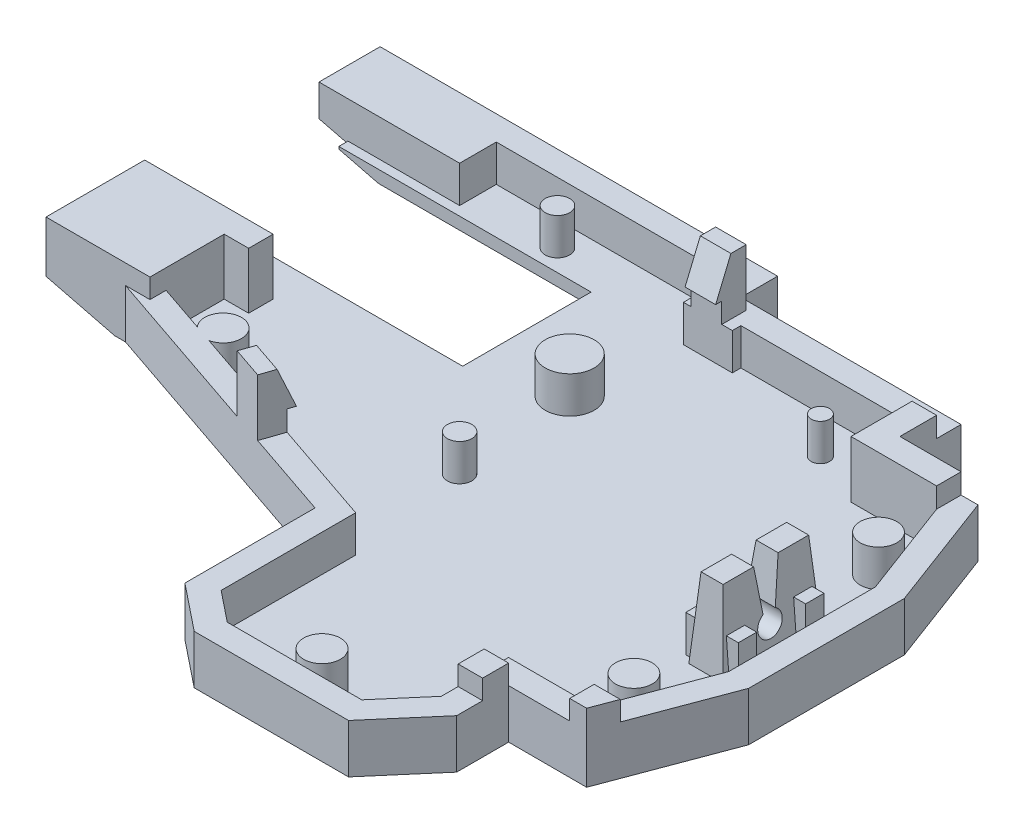
from build123d import *

# Parameters (mm, degrees)
SKETCH13_W           = 50
SKETCH13_H           = 45
BOSS_EXTRUDE4_DEPTH  = 1.6
SKETCH14_W           = 10
SKETCH14_H           = 8
CUT_EXTRUDE6_DEPTH   = 2.6
SKETCH15_W           = 18
SKETCH15_H           = 3
CUT_EXTRUDE7_DEPTH   = 2.6
SKETCH16_W           = 4
SKETCH16_H           = 0.7
CUT_EXTRUDE8_DEPTH   = 2.6
CUT_EXTRUDE9_DEPTH   = 2.6
SKETCH18_W           = 21.109590793
SKETCH18_H           = 22.840524871
CUT_EXTRUDE10_DEPTH  = 2.6
CUT_EXTRUDE11_DEPTH  = 2.6
SKETCH22_W           = 2
SKETCH22_H           = 3
CUT_EXTRUDE12_DEPTH  = 2.6
CUT_EXTRUDE13_DEPTH  = 2.6
CUT_EXTRUDE14_DEPTH  = 2.6
SKETCH25_W           = 2.8
SKETCH25_H           = 8
CUT_EXTRUDE15_DEPTH  = 2.6
BOSS_EXTRUDE6_DEPTH  = 6
SKETCH30_W           = 2.8
SKETCH30_H           = 8
BOSS_EXTRUDE7_DEPTH  = 3.5
CUT_EXTRUDE16_DEPTH  = 4.6
SKETCH32_W           = 2.8
SKETCH32_H           = 8
BOSS_EXTRUDE8_DEPTH  = 4.6
CUT_EXTRUDE18_DEPTH  = 4.6
SKETCH37_R           = 1
CUT_EXTRUDE19_DEPTH  = 4.6
CUT_EXTRUDE20_DEPTH  = 4.6
CUT_EXTRUDE21_START  = 6
CUT_EXTRUDE21_DEPTH  = 20.059798
BOSS_EXTRUDE9_DEPTH  = 4.6
SKETCH44_W           = 4.3
SKETCH44_H           = 1.5
BOSS_EXTRUDE11_DEPTH = 3
SKETCH45_R           = 1.5
SKETCH45_R_2         = 1
SKETCH45_R_3         = 1.999622229
SKETCH45_R_4         = 1.503341979
SKETCH45_R_5         = 0.75
BOSS_EXTRUDE12_DEPTH = 3
SKETCH46_W           = 2.5
SKETCH46_H           = 2
SKETCH46_W_2         = 2
BOSS_EXTRUDE13_DEPTH = 1.65
SKETCH47_W           = 3
SKETCH47_H           = 3
BOSS_EXTRUDE14_DEPTH = 3
SKETCH48_W           = 2
SKETCH48_H           = 16.336241737
CUT_EXTRUDE22_DEPTH  = 3
SKETCH49_W           = 21.336241737
SKETCH49_H           = 3
BOSS_EXTRUDE15_DEPTH = 13
SKETCH50_W           = 67
SKETCH50_H           = 49
BOSS_EXTRUDE16_DEPTH = 3
SKETCH51_W           = 5
SKETCH51_H           = 11
BOSS_EXTRUDE17_DEPTH = 15.6
CUT_EXTRUDE23_DEPTH  = 1.65
SKETCH53_W           = 2
SKETCH53_H           = 2.129349353
BOSS_EXTRUDE18_DEPTH = 1.6
SKETCH55_W           = 2.5
SKETCH55_H           = 2.5
BOSS_EXTRUDE20_DEPTH = 3
CUT_EXTRUDE24_DEPTH  = 3
SKETCH58_W           = 20
SKETCH58_H           = 10.5
SKETCH58_W_2         = 2
SKETCH58_H_2         = 2
CUT_EXTRUDE29_DEPTH  = 1
BOSS_EXTRUDE21_DEPTH = 3
BOSS_EXTRUDE22_REACH = 41.731
SKETCH61_W           = 2.5
SKETCH61_H           = 1.65
CUT_EXTRUDE30_DEPTH  = 3
CUT_EXTRUDE31_REACH  = 43.731
SKETCH64_W           = 2.551500858
SKETCH64_H           = 4.310788114
CUT_EXTRUDE32_DEPTH  = 4.65
SKETCH65_W           = 2
SKETCH65_H           = 2
BOSS_EXTRUDE23_DEPTH = 4
SKETCH66_W           = 2
SKETCH66_H           = 2
BOSS_EXTRUDE24_DEPTH = 1.6
SKETCH67_W           = 2.5
SKETCH67_H           = 2
BOSS_EXTRUDE25_DEPTH = 3
CUT_EXTRUDE33_DEPTH  = 3
BOSS_EXTRUDE26_DEPTH = 1.65
SKETCH70_W           = 5.055009343
SKETCH70_H           = 5.560438358
CUT_EXTRUDE34_DEPTH  = 3
BOSS_EXTRUDE27_DEPTH = 3
CUT_EXTRUDE35_DEPTH  = 3
BOSS_EXTRUDE28_REACH = 39.863
CUT_EXTRUDE36_DEPTH  = 3
FILLET8_R            = 1
SKETCH76_W           = 7
SKETCH76_H           = 14.5
BOSS_EXTRUDE29_DEPTH = 14.5
BOSS_EXTRUDE30_DEPTH = 2
CUT_EXTRUDE37_DEPTH  = 2
BOSS_EXTRUDE31_DEPTH = 2.684479
SKETCH85_W           = 30.566158209
SKETCH85_H           = 1.725230041
BOSS_EXTRUDE33_DEPTH = 3
BOSS_EXTRUDE34_DEPTH = 3
BOSS_EXTRUDE35_DEPTH = 3
SKETCH88_W           = 27.09375
SKETCH88_H           = 14.5
BOSS_EXTRUDE36_DEPTH = 1.6
SKETCH90_W           = 7
SKETCH90_H           = 14.5
BOSS_EXTRUDE37_DEPTH = 1.6
SKETCH93_W           = 5
SKETCH93_H           = 11
BOSS_EXTRUDE38_DEPTH = 0.5
SKETCH94_W           = 8.605758832
SKETCH94_H           = 2
BOSS_EXTRUDE39_DEPTH = 15.6
SKETCH96_W           = 8.605758832
SKETCH96_H           = 2
BOSS_EXTRUDE40_DEPTH = 0.5
SKETCH97_W           = 2
SKETCH97_H           = 49
BOSS_EXTRUDE41_DEPTH = 19.1
SKETCH98_W           = 69
SKETCH98_H           = 2
BOSS_EXTRUDE42_DEPTH = 19.1
SKETCH99_W           = 2
SKETCH99_H           = 3
BOSS_EXTRUDE43_DEPTH = 2.087376
SKETCH100_W          = 2
SKETCH100_H          = 51
BOSS_EXTRUDE45_DEPTH = 19.1
SKETCH101_W          = 71
SKETCH101_H          = 2
BOSS_EXTRUDE46_DEPTH = 19.1
BOSS_EXTRUDE47_DEPTH = 16.1
BOSS_EXTRUDE48_DEPTH = 16.1
FILLET9_R            = 2
SKETCH105_OUTSIDE_W  = 91.128
SKETCH105_OUTSIDE_H  = 73.128
CUT_EXTRUDE38_DEPTH  = 3
SKETCH106_W          = 77.0560479
SKETCH106_H          = 58.523580684
CUT_EXTRUDE39_DEPTH  = 20.1
SKETCH107_W          = 13.37564089
SKETCH107_H          = 6.179627402
CUT_EXTRUDE40_DEPTH  = 11.5
CUT_EXTRUDE41_DEPTH  = 4
SKETCH114_W          = 66.336817547
SKETCH114_H          = 51.668552302
CUT_EXTRUDE42_DEPTH  = 2
BOSS_EXTRUDE49_DEPTH = 6.5
SKETCH116_W          = 0.628599621
SKETCH116_H          = 10.5
CUT_EXTRUDE43_DEPTH  = 6.5
SKETCH117_W          = 8.5
SKETCH117_H          = 8.070282703
BOSS_EXTRUDE50_DEPTH = 1.6
SKETCH122_W          = 25.874774146
SKETCH122_H          = 74.423318024
CUT_EXTRUDE44_DEPTH  = 2.358414017


with BuildPart() as part:
    # Sketch13 → Boss-Extrude4 (new body)
    with BuildSketch(Plane(origin=(0, 0, 0), x_dir=(1, 0, 0), z_dir=(0, 1, 0))):
        with Locations((25, -22.5)):
            Rectangle(SKETCH13_W, SKETCH13_H)
    extrude(amount=BOSS_EXTRUDE4_DEPTH)

    # Sketch14 → Cut-Extrude6 (cut, through all)
    with BuildSketch(Plane(origin=(0, 1.6, 0), x_dir=(1, 0, 0), z_dir=(0, 1, 0))):
        with Locations((45, -4)):
            Rectangle(SKETCH14_W, SKETCH14_H)
    extrude(amount=-CUT_EXTRUDE6_DEPTH, mode=Mode.SUBTRACT)

    # Sketch15 → Cut-Extrude7 (cut, through all)
    with BuildSketch(Plane(origin=(0, 1.6, 0), x_dir=(1, 0, 0), z_dir=(0, 1, 0))):
        with Locations((31, -1.5)):
            Rectangle(SKETCH15_W, SKETCH15_H)
    extrude(amount=-CUT_EXTRUDE7_DEPTH, mode=Mode.SUBTRACT)

    # Sketch16 → Cut-Extrude8 (cut, through all)
    with BuildSketch(Plane(origin=(0, 1.6, 0), x_dir=(1, 0, 0), z_dir=(0, 1, 0))):
        with Locations((24, -3.35)):
            Rectangle(SKETCH16_W, SKETCH16_H)
    extrude(amount=-CUT_EXTRUDE8_DEPTH, mode=Mode.SUBTRACT)

    # Sketch17 → Cut-Extrude9 (cut, through all)
    with BuildSketch(Plane(origin=(0, 1.6, 0), x_dir=(1, 0, 0), z_dir=(0, 1, 0))):
        Polygon((47, -8), (50, -16), (65.881056194, -16), (65.881056194, 17.957346821), (47, 17.957346821), align=None)
    extrude(amount=-CUT_EXTRUDE9_DEPTH, mode=Mode.SUBTRACT)

    # Sketch18 → Cut-Extrude10 (cut, through all)
    with BuildSketch(Plane(origin=(0, 1.6, 0), x_dir=(1, 0, 0), z_dir=(0, 1, 0))):
        with Locations((50.554795396, -47.420262436)):
            Rectangle(SKETCH18_W, SKETCH18_H)
    extrude(amount=-CUT_EXTRUDE10_DEPTH, mode=Mode.SUBTRACT)

    # Sketch21 → Cut-Extrude11 (cut, through all)
    with BuildSketch(Plane(origin=(0, 1.6, 0), x_dir=(1, 0, 0), z_dir=(0, 1, 0))):
        Polygon((50, -28), (47, -36), (47, -49.297594069), (75.196774358, -49.297594069), (75.196774358, -28), align=None)
    extrude(amount=-CUT_EXTRUDE11_DEPTH, mode=Mode.SUBTRACT)

    # Sketch22 → Cut-Extrude12 (cut, through all)
    with BuildSketch(Plane(origin=(0, 1.6, 0), x_dir=(1, 0, 0), z_dir=(0, 1, 0))):
        with Locations((1, -20.836241737)):
            Rectangle(SKETCH22_W, SKETCH22_H)
    extrude(amount=-CUT_EXTRUDE12_DEPTH, mode=Mode.SUBTRACT)

    # Sketch23 → Cut-Extrude13 (cut, through all)
    with BuildSketch(Plane(origin=(0, 1.6, 0), x_dir=(1, 0, 0), z_dir=(0, 1, 0))):
        Polygon((23.5, -45), (23.5, -32), (0, -26.336241737), (-30.2261683, -26.336241737), (-30.2261683, -63.188280898), (23.5, -63.188280898), align=None)
    extrude(amount=-CUT_EXTRUDE13_DEPTH, mode=Mode.SUBTRACT)

    # Sketch24 → Cut-Extrude14 (cut, through all)
    with BuildSketch(Plane(origin=(0, 1.6, 0), x_dir=(1, 0, 0), z_dir=(0, 1, 0))):
        Polygon((23.5, -43), (7.491129632, -43), (7.491129632, -69.550234766), (44.754002286, -69.550234766), (44.754002286, -41.5), (40, -41.5), (37, -45), (26, -45), align=None)
    extrude(amount=-CUT_EXTRUDE14_DEPTH, mode=Mode.SUBTRACT)

    # Sketch25 → Cut-Extrude15 (cut, through all)
    with BuildSketch(Plane(origin=(0, 1.6, 0), x_dir=(1, 0, 0), z_dir=(0, 1, 0))):
        with Locations((46.200745069, -22.059797812)):
            Rectangle(SKETCH25_W, SKETCH25_H)
    extrude(amount=-CUT_EXTRUDE15_DEPTH, mode=Mode.SUBTRACT)

    # Sketch28 → Boss-Extrude6 (add)
    with BuildSketch(Plane.XZ):
        Polygon((42, 38), (42, 42.239848152), (37.919869845, 47), (25.298437881, 47), (21.5, 43.961249695), (21.5, 33.575244456), (-2, 27.911486193), (-2, -2), (24, -2), (24, 1), (42, 1), (42, 6), (48.386000936, 6), (52, 15.637330836), (52, 28.362669164), (48.386000936, 38), align=None)
    extrude(amount=BOSS_EXTRUDE6_DEPTH)

    # Sketch30 → Boss-Extrude7 (add)
    with BuildSketch(Plane(origin=(0, 0, 0), x_dir=(1, 0, 0), z_dir=(0, 1, 0))):
        with Locations((46.200745069, -22.059797812)):
            Rectangle(SKETCH30_W, SKETCH30_H)
    extrude(amount=BOSS_EXTRUDE7_DEPTH)

    # Sketch31 → Cut-Extrude16 (cut)
    with BuildSketch(Plane(origin=(0, 1.6, 0), x_dir=(1, 0, 0), z_dir=(0, 1, 0))):
        Polygon((37, -45), (40, -41.5), (40, -36), (47, -36), (50, -28), (50, -16), (47, -8), (40, -8), (40, -3), (26, -3), (26, -3.7), (22, -3.7), (22, 0), (0, 0), (0, -19.336241737), (2, -19.336241737), (2, -22.336241737), (0, -22.336241737), (0, -26.336241737), (23.5, -32), (23.5, -43), (26, -45), align=None)
    extrude(amount=-CUT_EXTRUDE16_DEPTH, mode=Mode.SUBTRACT)

    # Sketch32 → Boss-Extrude8 (add)
    with BuildSketch(Plane.XZ.offset(-1.6)):
        with Locations((46.200745069, 22.059797812)):
            Rectangle(SKETCH32_W, SKETCH32_H)
    extrude(amount=BOSS_EXTRUDE8_DEPTH)

    # Sketch35 → Cut-Extrude18 (cut)
    with BuildSketch(Plane(origin=(47.600745069, 0, 0), x_dir=(0, 0, -1), z_dir=(1, 0, 0))):
        Polygon((-22.059797812, 0), (-21.559797812, 0), (-21.059797812, 3.5), (-21.297672794, 5.165124873), (-23.257672794, 4.885124873), (-23.059797812, 3.5), (-22.559797812, 0), align=None)
    extrude(amount=-CUT_EXTRUDE18_DEPTH, mode=Mode.SUBTRACT)

    # Sketch37 → Cut-Extrude19 (cut)
    with BuildSketch(Plane(origin=(47.600745069, 0, 0), x_dir=(0, 0, -1), z_dir=(1, 0, 0))):
        with Locations((-22.059797812, -0.866025404)):
            Circle(SKETCH37_R)
    extrude(amount=-CUT_EXTRUDE19_DEPTH, mode=Mode.SUBTRACT)

    # Sketch39 → Cut-Extrude20 (cut)
    with BuildSketch(Plane.ZY.offset(-44.800745069)):
        Polygon((25.559797812, 3.5), (26.059797812, -3), (27.906381513, -2.8579551), (27.406381513, 3.6420449), align=None)
        Polygon((18.559797812, 3.5), (18.059797812, -3), (15.957253652, -2.838265834), (16.455739093, 3.6420449), align=None)
    extrude(amount=-CUT_EXTRUDE20_DEPTH, mode=Mode.SUBTRACT)

    # Sketch41 → Cut-Extrude21 (cut)
    with BuildSketch(Plane.XY.offset(CUT_EXTRUDE21_START)):
        Polygon((45.300745069, 3.5), (44.800745069, -3), (43.414957387, -2.893400947), (43.940591177, 3.939838325), align=None)
        Polygon((47.100745069, 3.5), (47.600745069, -3), (49.658968536, -2.841675118), (49.137313656, 3.939838325), align=None)
    extrude(amount=CUT_EXTRUDE21_DEPTH, mode=Mode.SUBTRACT)

    # Sketch43 → Boss-Extrude9 (add)
    with BuildSketch(Plane(origin=(0, 0, 0), x_dir=(1, 0, 0), z_dir=(0, 1, 0))):
        Polygon((47, -8), (50, -16), (51.170411472, -13.425094762), (48.386000936, -6), (42.818763345, -6), (42.818763345, -8), align=None)
    extrude(amount=-BOSS_EXTRUDE9_DEPTH)

    # Sketch44 → Boss-Extrude11 (add)
    with BuildSketch(Plane(origin=(0, -3, 0), x_dir=(1, 0, 0), z_dir=(0, 1, 0))):
        with Locations((46.200745069, -19.309797812)):
            Rectangle(SKETCH44_W, SKETCH44_H)
        with Locations((46.200745069, -24.809797812)):
            Rectangle(SKETCH44_W, SKETCH44_H)
    extrude(amount=BOSS_EXTRUDE11_DEPTH)

    # Sketch45 → Boss-Extrude12 (add)
    with BuildSketch(Plane(origin=(0, -3, 0), x_dir=(1, 0, 0), z_dir=(0, 1, 0))):
        with Locations((46.25, -12)):
            Circle(SKETCH45_R)
        with Locations((46.25, -32)):
            Circle(SKETCH45_R)
        with Locations((22, -22)):
            Circle(SKETCH45_R_2)
        with Locations((21, -12)):
            Circle(SKETCH45_R_3)
        with Locations((31.75, -43)):
            Circle(SKETCH45_R_4)
        with Locations((35.5, -6)):
            Circle(SKETCH45_R_5)
        with Locations((10, -2)):
            Circle(SKETCH45_R_2)
        with Locations((5, -24.336241737)):
            Circle(SKETCH45_R)
    extrude(amount=BOSS_EXTRUDE12_DEPTH)

    # Sketch46 → Boss-Extrude13 (add)
    with BuildSketch(Plane(origin=(0, 0, 0), x_dir=(1, 0, 0), z_dir=(0, 1, 0))):
        Polygon((14.137316506, -29.743490383), (16.567726059, -30.329245795), (16.099121729, -32.273573438), (13.668712176, -31.687818026), align=None)
        with Locations((23.883625006, -2.7)):
            Rectangle(SKETCH46_W, SKETCH46_H)
        with Locations((1, -20.932723283)):
            Rectangle(SKETCH46_W_2, SKETCH46_H)
        Polygon((47, -36), (48.872658355, -36.702246883), (49.750466959, -34.361423939), (47.877808604, -33.659177056), align=None)
        Polygon((40, -3), (40, -8), (47, -8), (47, -6), (42, -6), (42, -3), align=None)
    extrude(amount=BOSS_EXTRUDE13_DEPTH)

    # Sketch47 → Boss-Extrude14 (add)
    with BuildSketch(Plane(origin=(0, 0, 0), x_dir=(1, 0, 0), z_dir=(0, 1, 0))):
        with Locations((1.5, -1.5)):
            Rectangle(SKETCH47_W, SKETCH47_H)
    extrude(amount=-BOSS_EXTRUDE14_DEPTH)

    # Sketch48 → Cut-Extrude22 (cut)
    with BuildSketch(Plane(origin=(0, 0, 0), x_dir=(1, 0, 0), z_dir=(0, 1, 0))):
        with Locations((-1, -11.168120869)):
            Rectangle(SKETCH48_W, SKETCH48_H)
    extrude(amount=-CUT_EXTRUDE22_DEPTH, mode=Mode.SUBTRACT)

    # Sketch49 → Boss-Extrude15 (add)
    with BuildSketch(Plane.ZY.offset(2)):
        with Locations((8.668120869, -4.5)):
            Rectangle(SKETCH49_W, SKETCH49_H)
    extrude(amount=BOSS_EXTRUDE15_DEPTH)

    # Sketch50 → Boss-Extrude16 (add)
    with BuildSketch(Plane.XZ.offset(6)):
        with Locations((18.5, 22.5)):
            Rectangle(SKETCH50_W, SKETCH50_H)
    extrude(amount=-BOSS_EXTRUDE16_DEPTH)

    # Sketch51 → Boss-Extrude17 (add)
    with BuildSketch(Plane(origin=(0, -3, 0), x_dir=(1, 0, 0), z_dir=(0, 1, 0))):
        with Locations((49.5, -41.5)):
            Rectangle(SKETCH51_W, SKETCH51_H)
    extrude(amount=BOSS_EXTRUDE17_DEPTH)

    # Sketch52 → Cut-Extrude23 (cut)
    with BuildSketch(Plane(origin=(0, 1.65, 0), x_dir=(1, 0, 0), z_dir=(0, 1, 0))):
        Polygon((47.877808604, -33.659177056), (47, -36), (49.136000936, -36), (49.750466959, -34.361423939), align=None)
    extrude(amount=-CUT_EXTRUDE23_DEPTH, mode=Mode.SUBTRACT)

    # Sketch53 → Boss-Extrude18 (add)
    with BuildSketch(Plane(origin=(0, 0, 0), x_dir=(1, 0, 0), z_dir=(0, 1, 0))):
        with Locations((41, -39.055249399)):
            Rectangle(SKETCH53_W, SKETCH53_H)
    extrude(amount=BOSS_EXTRUDE18_DEPTH)

    # Sketch55 → Boss-Extrude20 (add)
    with BuildSketch(Plane(origin=(0, 1.65, 0), x_dir=(1, 0, 0), z_dir=(0, 1, 0))):
        with Locations((23.883625006, -2.95)):
            Rectangle(SKETCH55_W, SKETCH55_H)
    extrude(amount=BOSS_EXTRUDE20_DEPTH)

    # Sketch56 → Cut-Extrude24 (cut)
    with BuildSketch(Plane(origin=(25.133625006, 0, 0), x_dir=(0, 0, -1), z_dir=(1, 0, 0))):
        Polygon((-4.2, 1.65), (-2.95, 4.65), (-2.95, 7.68728323), (-6.59715338, 7.68728323), (-6.59715338, 1.641289328), align=None)
    extrude(amount=-CUT_EXTRUDE24_DEPTH, mode=Mode.SUBTRACT)

    # Sketch58 → Cut-Extrude29 (cut)
    with BuildSketch(Plane(origin=(0, -3, 0), x_dir=(1, 0, 0), z_dir=(0, 1, 0))):
        with Locations((4.5, -9)):
            Rectangle(SKETCH58_W, SKETCH58_H)
        with Locations((1, -18.248866233)):
            Rectangle(SKETCH58_W_2, SKETCH58_H_2)
    extrude(amount=-CUT_EXTRUDE29_DEPTH, mode=Mode.SUBTRACT)

    # Sketch60 → Boss-Extrude21 (add)
    with BuildSketch(Plane(origin=(0, -3, 0), x_dir=(1, 0, 0), z_dir=(0, 1, 0))):
        Polygon((0, -24), (23.5, -32), (0, -26.336241737), align=None)
    extrude(amount=BOSS_EXTRUDE21_DEPTH)

    # Boss-Extrude22: up to this face of the body (flat: up to its plane)
    boss_extrude22_end = Plane(part.part.faces().sort_by_distance((14.401539714, -1.5, 28.902651818))[0])
    # Sketch61 → Boss-Extrude22 (add, up to the picked face)
    with BuildSketch(Plane(origin=(-5.998871461, 0, 24.890447788), x_dir=(-0.972163821, 0, -0.234302165), z_dir=(0.234302165, 0, -0.972163821)), mode=Mode.PRIVATE) as boss_extrude22_sk1:
        with Locations((-21.962751827, 0.825)):
            Rectangle(SKETCH61_W, SKETCH61_H)
    boss_extrude22_tool1 = split(extrude(boss_extrude22_sk1.sketch, amount=BOSS_EXTRUDE22_REACH, mode=Mode.PRIVATE), bisect_by=boss_extrude22_end, keep=Keep.BOTH, mode=Mode.PRIVATE)
    add(boss_extrude22_tool1.solids().sort_by_distance((15.352521, 0.825, 30.036368))[0])

    # Sketch62 → Cut-Extrude30 (cut)
    with BuildSketch(Plane(origin=(0, 0, 0), x_dir=(1, 0, 0), z_dir=(0, 1, 0))):
        Polygon((0, -26), (-0.545193502, -28.262110548), (-9.931116312, -26), (-9.25988925, -22.847697277), align=None)
    extrude(amount=-CUT_EXTRUDE30_DEPTH, mode=Mode.SUBTRACT)

    # Cut-Extrude31: up to this face of the body (flat: up to its plane)
    cut_extrude31_end = Plane(part.part.faces().sort_by_distance((-1, -1.5, 25.659574468))[0])
    # Sketch63 → Cut-Extrude31 (cut, up to the picked face)
    with BuildSketch(Plane(origin=(-6.46747579, 0, 26.834775431), x_dir=(0.972163821, 0, 0.234302165), z_dir=(-0.234302165, 0, 0.972163821)), mode=Mode.PRIVATE) as cut_extrude31_sk1:
        Polygon((20.712751827, 0), (6.091856288, 0), (6.091856288, -3), (28.768274623, -3), (28.768274623, 0), (23.212751827, 0), (23.212751827, 1.65), (20.712751827, 1.65), align=None)
    cut_extrude31_tool1 = split(extrude(cut_extrude31_sk1.sketch, amount=-CUT_EXTRUDE31_REACH, mode=Mode.PRIVATE), bisect_by=cut_extrude31_end, keep=Keep.BOTH, mode=Mode.PRIVATE)
    add(cut_extrude31_tool1.solids().sort_by_distance((10.72932, -1.367082, 30.979392))[0], mode=Mode.SUBTRACT)

    # Sketch64 → Cut-Extrude32 (cut)
    with BuildSketch(Plane(origin=(0, 1.65, 0), x_dir=(1, 0, 0), z_dir=(0, 1, 0))):
        with Locations((1.275750429, -20.806985271)):
            Rectangle(SKETCH64_W, SKETCH64_H)
    extrude(amount=-CUT_EXTRUDE32_DEPTH, mode=Mode.SUBTRACT)

    # Sketch65 → Boss-Extrude23 (add)
    with BuildSketch(Plane(origin=(0, -4, 0), x_dir=(1, 0, 0), z_dir=(0, 1, 0))):
        with Locations((1, -18.248866233)):
            Rectangle(SKETCH65_W, SKETCH65_H)
    extrude(amount=BOSS_EXTRUDE23_DEPTH)

    # Sketch66 → Boss-Extrude24 (add)
    with BuildSketch(Plane(origin=(0, 0, 0), x_dir=(1, 0, 0), z_dir=(0, 1, 0))):
        with Locations((1, -18.248866233)):
            Rectangle(SKETCH66_W, SKETCH66_H)
    extrude(amount=BOSS_EXTRUDE24_DEPTH)

    # Sketch67 → Boss-Extrude25 (add)
    with BuildSketch(Plane(origin=(0, 1.6, 0), x_dir=(1, 0, 0), z_dir=(0, 1, 0))):
        with Locations((1.25, -18.248866233)):
            Rectangle(SKETCH67_W, SKETCH67_H)
    extrude(amount=BOSS_EXTRUDE25_DEPTH)

    # Sketch68 → Cut-Extrude33 (cut)
    with BuildSketch(Plane(origin=(0, 0, 17.248866233), x_dir=(-1, 0, 0), z_dir=(0, 0, -1))):
        Polygon((-2.5, 1.6), (-1.25, 4.6), (-1.25, 6.77486743), (-4.497451498, 6.77486743), (-4.497451498, 1.567063174), align=None)
    extrude(amount=-CUT_EXTRUDE33_DEPTH, mode=Mode.SUBTRACT)

    # Sketch69 → Boss-Extrude26 (add)
    with BuildSketch(Plane(origin=(0, 1.65, 0), x_dir=(1, 0, 0), z_dir=(0, 1, 0))):
        Polygon((14.344636536, -28.883280523), (16.885898362, -29.748390932), (16.275756374, -31.540683021), (13.734494548, -30.675572612), align=None)
    extrude(amount=-BOSS_EXTRUDE26_DEPTH)

    # Sketch70 → Cut-Extrude34 (cut)
    with BuildSketch(Plane.XY.offset(19.248866233)):
        with Locations((-0.027504672, 4.380219179)):
            Rectangle(SKETCH70_W, SKETCH70_H)
    extrude(amount=-CUT_EXTRUDE34_DEPTH, mode=Mode.SUBTRACT)

    # Sketch71 → Boss-Extrude27 (add)
    with BuildSketch(Plane(origin=(0, 1.65, 0), x_dir=(1, 0, 0), z_dir=(0, 1, 0))):
        Polygon((16.275756374, -31.540683021), (17.081415869, -29.174058256), (14.559846057, -28.298525857), (13.734494548, -30.675572612), align=None)
    extrude(amount=BOSS_EXTRUDE27_DEPTH)

    # Sketch72 → Cut-Extrude35 (cut)
    with BuildSketch(Plane(origin=(24.207602216, 0, 8.240885861), x_dir=(0.322263798, 0, -0.946649906), z_dir=(0.946649906, 0, 0.322263798))):
        Polygon((-22.112897557, 1.65), (-23.362897557, 4.65), (-23.362897557, 7.694800469), (-20.734818485, 7.694800469), (-20.734818485, 1.65), align=None)
    extrude(amount=-CUT_EXTRUDE35_DEPTH, mode=Mode.SUBTRACT)

    # Boss-Extrude28: up to this face of the body (flat: up to its plane)
    boss_extrude28_end = Plane(part.part.faces().sort_by_distance((14.039565542, 0.825, 29.779426567))[0])
    # Sketch73 → Boss-Extrude28 (add, up to the picked face)
    with BuildSketch(Plane(origin=(21.761963317, 0, 7.556127878), x_dir=(-0.328007452, 0, 0.944675136), z_dir=(-0.944675136, 0, -0.328007452)), mode=Mode.PRIVATE) as boss_extrude28_sk1:
        Polygon((24.473434161, 4.65), (23.223411105, 4.65), (21.973388049, 1.65), (22.580099427, 1.65), (24.473434161, 1.65), align=None)
    boss_extrude28_tool1 = split(extrude(boss_extrude28_sk1.sketch, amount=BOSS_EXTRUDE28_REACH, mode=Mode.PRIVATE), bisect_by=boss_extrude28_end, keep=Keep.BOTH, mode=Mode.PRIVATE)
    add(boss_extrude28_tool1.solids().sort_by_distance((14.053397, 2.983333, 29.757122))[0])

    # Sketch74 → Cut-Extrude36 (cut)
    with BuildSketch(Plane(origin=(0, -4, 0), x_dir=(1, 0, 0), z_dir=(0, 1, 0))):
        with BuildLine():
            Line((6.419171569, -6.169171569), (2.580828431, -6.169171569))
            ThreePointArc((2.580828431, -6.169171569), (-0.25, -9), (2.580828431, -11.830828431))
            Line((2.580828431, -11.830828431), (6.419171569, -11.830828431))
            ThreePointArc((6.419171569, -11.830828431), (9.25, -9), (6.419171569, -6.169171569))
        make_face()
    extrude(amount=-CUT_EXTRUDE36_DEPTH, mode=Mode.SUBTRACT)

    # Fillet8
    fillet8_edges = [part.edges().sort_by_distance(p)[0] for p in [
        (-0.25, -6, 9),
        (4.5, -6, 6.169171569),
        (9.25, -6, 9),
        (4.5, -6, 11.830828431),
    ]]
    fillet(fillet8_edges, radius=FILLET8_R)

    # Sketch76 → Boss-Extrude29 (add)
    with BuildSketch(Plane(origin=(0, -3, 0), x_dir=(1, 0, 0), z_dir=(0, 1, 0))):
        with Locations((-11.5, -39.75)):
            Rectangle(SKETCH76_W, SKETCH76_H)
    extrude(amount=BOSS_EXTRUDE29_DEPTH)

    # Sketch79 → Boss-Extrude30 (add)
    with BuildSketch(Plane(origin=(21.66634039, 0, 7.375775452), x_dir=(-0.322263798, 0, 0.946649906), z_dir=(-0.946649906, 0, -0.322263798))):
        Polygon((22.719597745, 0), (24.612897557, 0), (24.612897557, 4.65), (23.362851444, 4.65), (22.112805332, 1.65), (22.719597745, 1.65), align=None)
    extrude(amount=BOSS_EXTRUDE30_DEPTH)

    # Sketch80 → Cut-Extrude37 (cut)
    with BuildSketch(Plane(origin=(24.207602216, 0, 8.240885861), x_dir=(0.322263798, 0, -0.946649906), z_dir=(0.946649906, 0, 0.322263798))):
        Polygon((-22.112897557, 1.65), (-23.362897557, 4.65), (-24.612897557, 4.65), (-24.612897557, 0), (-22.719597745, 0), (-22.719597745, 1.65), align=None)
    extrude(amount=-CUT_EXTRUDE37_DEPTH, mode=Mode.SUBTRACT)

    # Sketch83 → Boss-Extrude31 (add)
    with BuildSketch(Plane(origin=(19.773040578, 0, 6.731247856), x_dir=(-0.322263798, 0, 0.946649906), z_dir=(-0.946649906, 0, -0.322263798))):
        Polygon((22.719597745, 1.65), (22.719597745, 0), (24.612897557, 0), (24.612897557, 4.65), (23.362851444, 4.65), (22.112805332, 1.65), align=None)
    extrude(amount=-BOSS_EXTRUDE31_DEPTH)

    # Sketch85 → Boss-Extrude33 (add)
    with BuildSketch(Plane(origin=(0, -3, 0), x_dir=(1, 0, 0), z_dir=(0, 1, 0))):
        with Locations((7.283079105, -33.362615021)):
            Rectangle(SKETCH85_W, SKETCH85_H)
    extrude(amount=BOSS_EXTRUDE33_DEPTH)

    # Sketch86 → Boss-Extrude34 (add)
    with BuildSketch(Plane(origin=(0, -3, 0), x_dir=(1, 0, 0), z_dir=(0, 1, 0))):
        Polygon((21.5, -43.961249695), (21.5, -34.225230041), (-8, -34.225230041), (-8, -47), (25.298437881, -47), align=None)
    extrude(amount=BOSS_EXTRUDE34_DEPTH)

    # Sketch87 → Boss-Extrude35 (add)
    with BuildSketch(Plane(origin=(0, -3, 0), x_dir=(1, 0, 0), z_dir=(0, 1, 0))):
        Polygon((37.919869845, -47), (47, -47), (47, -38), (42, -38), (42, -42.239848152), align=None)
    extrude(amount=BOSS_EXTRUDE35_DEPTH)

    # Sketch88 → Boss-Extrude36 (add)
    with BuildSketch(Plane(origin=(0, 0, 0), x_dir=(1, 0, 0), z_dir=(0, 1, 0))):
        with Locations((5.546875, -39.75)):
            Rectangle(SKETCH88_W, SKETCH88_H)
    extrude(amount=BOSS_EXTRUDE36_DEPTH)

    # Sketch90 → Boss-Extrude37 (add)
    with BuildSketch(Plane(origin=(0, 11.5, 0), x_dir=(1, 0, 0), z_dir=(0, 1, 0))):
        with Locations((-11.5, -39.75)):
            Rectangle(SKETCH90_W, SKETCH90_H)
    extrude(amount=BOSS_EXTRUDE37_DEPTH)

    # Sketch93 → Boss-Extrude38 (add)
    with BuildSketch(Plane(origin=(0, 12.6, 0), x_dir=(1, 0, 0), z_dir=(0, 1, 0))):
        with Locations((49.5, -41.5)):
            Rectangle(SKETCH93_W, SKETCH93_H)
    extrude(amount=BOSS_EXTRUDE38_DEPTH)

    # Sketch94 → Boss-Extrude39 (add)
    with BuildSketch(Plane(origin=(0, -3, 0), x_dir=(1, 0, 0), z_dir=(0, 1, 0))):
        with Locations((5.421445221, -31.5)):
            Rectangle(SKETCH94_W, SKETCH94_H)
    extrude(amount=BOSS_EXTRUDE39_DEPTH)

    # Sketch96 → Boss-Extrude40 (add)
    with BuildSketch(Plane(origin=(0, 12.6, 0), x_dir=(1, 0, 0), z_dir=(0, 1, 0))):
        with Locations((5.421445221, -31.5)):
            Rectangle(SKETCH96_W, SKETCH96_H)
    extrude(amount=BOSS_EXTRUDE40_DEPTH)

    # Sketch97 → Boss-Extrude41 (add)
    with BuildSketch(Plane.XZ.offset(6)):
        with Locations((-16, 22.5)):
            Rectangle(SKETCH97_W, SKETCH97_H)
    extrude(amount=-BOSS_EXTRUDE41_DEPTH)

    # Sketch98 → Boss-Extrude42 (add)
    with BuildSketch(Plane.XZ.offset(6)):
        with Locations((17.5, 48)):
            Rectangle(SKETCH98_W, SKETCH98_H)
    extrude(amount=-BOSS_EXTRUDE42_DEPTH)

    # Sketch99 → Boss-Extrude43 (add)
    with BuildSketch(Plane(origin=(0, 0, 19.336241737), x_dir=(-1, 0, 0), z_dir=(0, 0, -1))):
        with Locations((1, -1.5)):
            Rectangle(SKETCH99_W, SKETCH99_H)
    extrude(amount=BOSS_EXTRUDE43_DEPTH)

    # Sketch100 → Boss-Extrude45 (add)
    with BuildSketch(Plane.XZ.offset(6)):
        with Locations((53, 23.5)):
            Rectangle(SKETCH100_W, SKETCH100_H)
    extrude(amount=-BOSS_EXTRUDE45_DEPTH)

    # Sketch101 → Boss-Extrude46 (add)
    with BuildSketch(Plane.XZ.offset(6)):
        with Locations((18.5, -3)):
            Rectangle(SKETCH101_W, SKETCH101_H)
    extrude(amount=-BOSS_EXTRUDE46_DEPTH)

    # Sketch102 → Boss-Extrude47 (add)
    with BuildSketch(Plane(origin=(0, -3, 0), x_dir=(1, 0, 0), z_dir=(0, 1, 0))):
        with BuildLine():
            Line((50, 2), (50, 2.836676417))
            Line((50, 2.836676417), (52.928518438, 2.836676417))
            Line((52.928518438, 2.836676417), (52.928518438, 0))
            Line((52.928518438, 0), (52, 0))
            ThreePointArc((52, 0), (51.414213562, 1.414213562), (50, 2))
        make_face()
    extrude(amount=BOSS_EXTRUDE47_DEPTH)

    # Sketch103 → Boss-Extrude48 (add)
    with BuildSketch(Plane(origin=(0, -3, 0), x_dir=(1, 0, 0), z_dir=(0, 1, 0))):
        with BuildLine():
            Line((-13, 2), (-13, 3.319267165))
            Line((-13, 3.319267165), (-16.315139414, 3.319267165))
            Line((-16.315139414, 3.319267165), (-16.315139414, 0))
            Line((-16.315139414, 0), (-15, 0))
            ThreePointArc((-15, 0), (-14.414213562, 1.414213562), (-13, 2))
        make_face()
    extrude(amount=BOSS_EXTRUDE48_DEPTH)

    # Fillet9
    fillet9_edges = [part.edges().sort_by_distance(p)[0] for p in [
        (-17, -6, 22.5),
        (18.5, -6, 49),
        (-17, 3.55, 49),
        (54, -6, 22.5),
        (54, 3.55, 49),
        (18.5, -6, -4),
        (-17, 3.55, -4),
        (54, 3.55, -4),
    ]]
    fillet(fillet9_edges, radius=FILLET9_R)

    # Sketch105 outside → Cut-Extrude38 (cut)
    with BuildSketch(Plane(origin=(0, 13.1, 0), x_dir=(1, 0, 0), z_dir=(0, 1, 0))):
        with Locations((18.5, -22.5)):
            Rectangle(SKETCH105_OUTSIDE_W, SKETCH105_OUTSIDE_H)
        with BuildLine():
            Line((-16, 2), (-16, -47))
            ThreePointArc((-16, -47), (-15.707106781, -47.707106781), (-15, -48))
            Line((-15, -48), (52, -48))
            ThreePointArc((52, -48), (52.707106781, -47.707106781), (53, -47))
            Line((53, -47), (53, 2))
            ThreePointArc((53, 2), (52.707106781, 2.707106781), (52, 3))
            Line((52, 3), (-15, 3))
            ThreePointArc((-15, 3), (-15.707106781, 2.707106781), (-16, 2))
        make_face(mode=Mode.SUBTRACT)
    extrude(amount=-CUT_EXTRUDE38_DEPTH, mode=Mode.SUBTRACT)

    # Sketch106 → Cut-Extrude39 (cut, through all)
    with BuildSketch(Plane.XZ.offset(6)):
        with Locations((17.692589571, 21.631481201)):
            Rectangle(SKETCH106_W, SKETCH106_H)
        Polygon((-2, -2), (24, -2), (24, 1), (42, 1), (42, 6), (48.386000936, 6), (52, 15.637330836), (52, 28.362669164), (49.136000936, 36), (48.386000936, 38), (42, 37.990574723), (42, 42.239848152), (37.919869845, 47), (25.298437881, 47), (21.5, 43.961249695), (21.5, 33.319148936), (-2, 25.319148936), (-2, 17.248866233), (-8.372079234, 17.248866233), (-8.372079234, 3), (-2, 3), align=None, mode=Mode.SUBTRACT)
    extrude(amount=-CUT_EXTRUDE39_DEPTH, mode=Mode.SUBTRACT)

    # Sketch107 → Cut-Extrude40 (cut)
    with BuildSketch(Plane(origin=(0, 13.1, 0), x_dir=(1, 0, 0), z_dir=(0, 1, 0))):
        with Locations((44.784273424, -38.274312053)):
            Rectangle(SKETCH107_W, SKETCH107_H)
    extrude(amount=-CUT_EXTRUDE40_DEPTH, mode=Mode.SUBTRACT)

    # Sketch113 → Cut-Extrude41 (cut, through all)
    with BuildSketch(Plane(origin=(0, -3, 0), x_dir=(1, 0, 0), z_dir=(0, 1, 0))):
        Polygon((-6.128599621, -3), (-6.128599621, -14.861393841), (-2, -14.861393841), (-2, -17.248866233), (-9.246534053, -26.452427809), (-13.814435406, -0.657200841), (-2.974123127, 6.68981616), (-3.537653946, 5.974095989), align=None)
    extrude(amount=-CUT_EXTRUDE41_DEPTH, mode=Mode.SUBTRACT)

    # Sketch114 → Cut-Extrude42 (cut)
    with BuildSketch(Plane.XZ.offset(6)):
        with Locations((24.645555619, 22.809022442)):
            Rectangle(SKETCH114_W, SKETCH114_H)
    extrude(amount=-CUT_EXTRUDE42_DEPTH, mode=Mode.SUBTRACT)

    # Sketch115 → Boss-Extrude49 (add)
    with BuildSketch(Plane.ZY.offset(2)):
        Polygon((14.861393841, -3), (14.861393841, -4), (25.319148936, -4), (25.319148936, 0), (17.248866233, 0), (17.248866233, -3), align=None)
        Polygon((-2, 0), (-2, -4), (3, -4), (3, -3), (3, 0), align=None)
    extrude(amount=BOSS_EXTRUDE49_DEPTH)

    # Sketch116 → Cut-Extrude43 (cut)
    with BuildSketch(Plane(origin=(0, -3, 0), x_dir=(1, 0, 0), z_dir=(0, 1, 0))):
        with Locations((-5.81429981, -9)):
            Rectangle(SKETCH116_W, SKETCH116_H)
    extrude(amount=-CUT_EXTRUDE43_DEPTH, mode=Mode.SUBTRACT)

    # Sketch117 → Boss-Extrude50 (add)
    with BuildSketch(Plane(origin=(0, 0, 0), x_dir=(1, 0, 0), z_dir=(0, 1, 0))):
        with Locations((-4.25, -21.284007585)):
            Rectangle(SKETCH117_W, SKETCH117_H)
    extrude(amount=BOSS_EXTRUDE50_DEPTH)

    # Sketch122 → Cut-Extrude44 (cut, through all)
    with BuildSketch(Plane(origin=(-1.107785762, -4.443086013, 0), x_dir=(0.970295726, -0.241921896, 0), z_dir=(0.241921896, 0.970295726, 0))):
        with Locations((-2.201045184, -25.920604001)):
            Rectangle(SKETCH122_W, SKETCH122_H)
    extrude(amount=-CUT_EXTRUDE44_DEPTH, mode=Mode.SUBTRACT)


solid = part.part
